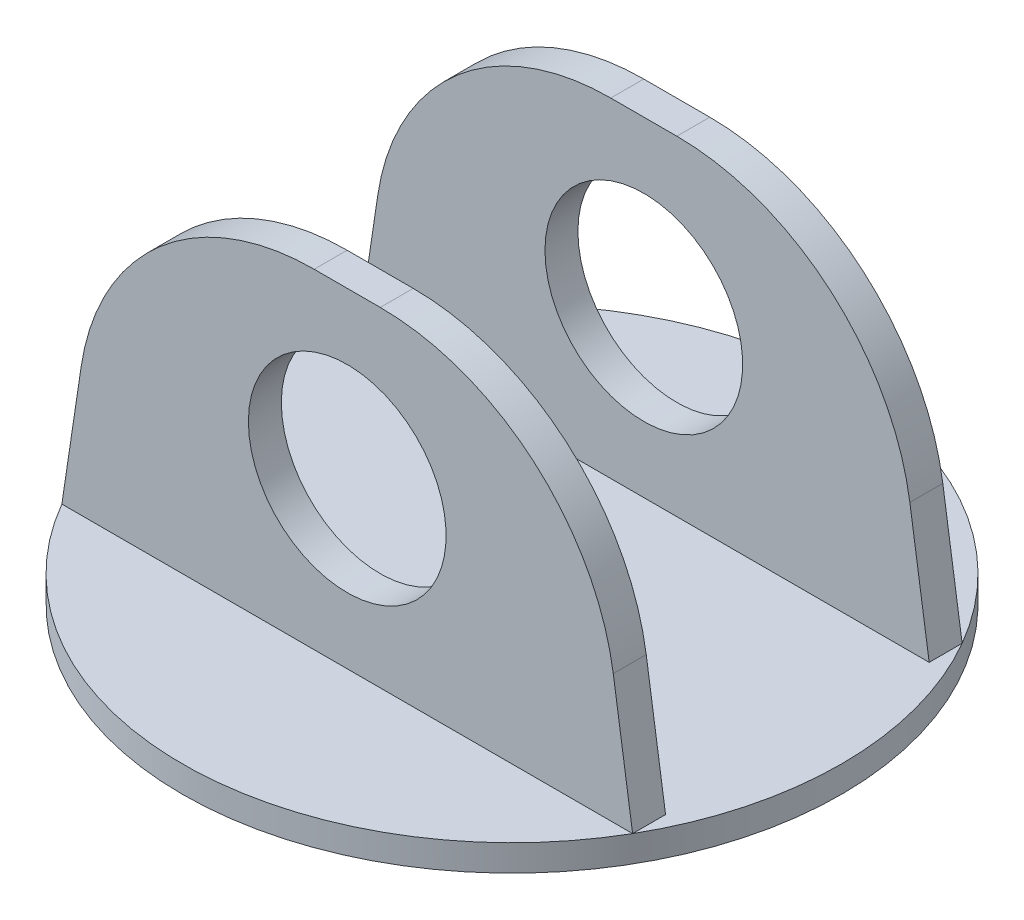
from build123d import *

# Parameters (mm, degrees)
SKETCH2_R           = 50.8
BOSS_EXTRUDE1_DEPTH = 4.064
SKETCH3_W           = 87.988181024
SKETCH3_H           = 5.08
BOSS_EXTRUDE2_DEPTH = 50.8
CUT_EXTRUDE2_DEPTH  = 77.2
FILLET1_R           = 36.322
SKETCH6_R           = 15.24
CUT_EXTRUDE3_DEPTH  = 77.2
SKETCH7_R           = 3.175
CUT_EXTRUDE4_DEPTH  = 5.064


with BuildPart() as part:
    # Sketch2 → Boss-Extrude1 (new body)
    with BuildSketch(Plane(origin=(0, 0, 0), x_dir=(1, 0, 0), z_dir=(0, 1, 0))):
        Circle(SKETCH2_R)
    extrude(amount=BOSS_EXTRUDE1_DEPTH)

    # Sketch3 → Boss-Extrude2 (add)
    with BuildSketch(Plane(origin=(0, 4.064, 0), x_dir=(1, 0, 0), z_dir=(0, 1, 0))):
        with Locations((0, -22.86)):
            Rectangle(SKETCH3_W, SKETCH3_H)
        with Locations((0, 22.86)):
            Rectangle(SKETCH3_W, SKETCH3_H)
    extrude(amount=BOSS_EXTRUDE2_DEPTH)

    # Sketch5 → Cut-Extrude2 (cut, through all)
    with BuildSketch(Plane(origin=(0, 0, -25.4), x_dir=(-1, 0, 0), z_dir=(0, 0, -1))):
        Polygon((-43.994090512, 4.064), (-43.994090512, 54.864), (-36.374090512, 54.864), align=None)
        Polygon((43.994090512, 4.064), (36.374090512, 54.864), (43.994090512, 54.864), align=None)
    extrude(amount=-CUT_EXTRUDE2_DEPTH, mode=Mode.SUBTRACT)

    # Fillet1
    fillet1_edges = [part.edges().sort_by_distance(p)[0] for p in [
        (36.374090512, 54.864, -22.86),
        (36.374090512, 54.864, 22.86),
        (-36.374090512, 54.864, -22.86),
        (-36.374090512, 54.864, 22.86),
    ]]
    fillet(fillet1_edges, radius=FILLET1_R)

    # Sketch6 → Cut-Extrude3 (cut, through all)
    with BuildSketch(Plane(origin=(0, 0, -25.4), x_dir=(-1, 0, 0), z_dir=(0, 0, -1))):
        with Locations((0, 29.464)):
            Circle(SKETCH6_R)
    extrude(amount=-CUT_EXTRUDE3_DEPTH, mode=Mode.SUBTRACT)

    # Sketch7 → Cut-Extrude4 (cut, through all)
    with BuildSketch(Plane(origin=(0, 4.064, 0), x_dir=(1, 0, 0), z_dir=(0, 1, 0))):
        Circle(SKETCH7_R)
    extrude(amount=-CUT_EXTRUDE4_DEPTH, mode=Mode.SUBTRACT)


solid = part.part
